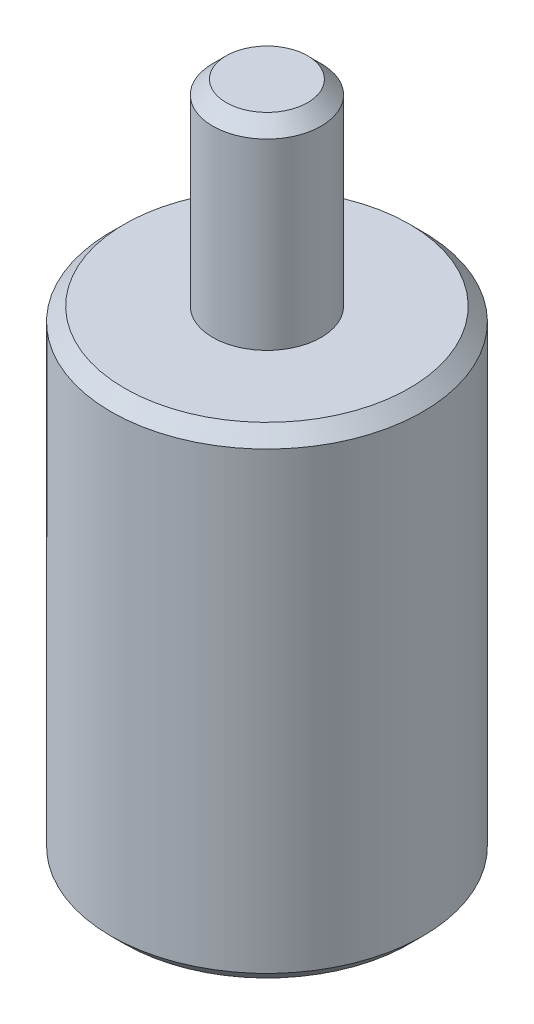
from build123d import *

# Parameters (mm, degrees)
SKETCH1_R           = 1.15
BOSS_EXTRUDE1_DEPTH = 5
SKETCH2_OUTSIDE_W   = 5.492
SKETCH2_OUTSIDE_H   = 5.492
SKETCH2_OUTSIDE_R   = 0.4
CUT_EXTRUDE1_DEPTH  = 1.45
CHAMFER1_SIZE       = 0.1
CHAMFER2_SIZE       = 0.1


with BuildPart() as part:
    # Sketch1 → Boss-Extrude1 (new body)
    with BuildSketch(Plane(origin=(0, 0, 0), x_dir=(1, 0, 0), z_dir=(0, 1, 0))):
        Circle(SKETCH1_R)
    extrude(amount=BOSS_EXTRUDE1_DEPTH)

    # Sketch2 outside → Cut-Extrude1 (cut)
    with BuildSketch(Plane(origin=(0, 5, 0), x_dir=(1, 0, 0), z_dir=(0, 1, 0))):
        Rectangle(SKETCH2_OUTSIDE_W, SKETCH2_OUTSIDE_H)
        Circle(SKETCH2_OUTSIDE_R, mode=Mode.SUBTRACT)
    extrude(amount=-CUT_EXTRUDE1_DEPTH, mode=Mode.SUBTRACT)

    # Chamfer1
    chamfer1_edges = [part.edges().sort_by_distance(p)[0] for p in [
        (-1.15, 0, 0),
        (-1.15, 3.55, 0),
    ]]
    chamfer(chamfer1_edges, length=CHAMFER1_SIZE)

    # Chamfer2
    chamfer2_edges = [part.edges().sort_by_distance(p)[0] for p in [
        (-0.4, 5, 0),
    ]]
    chamfer(chamfer2_edges, length=CHAMFER2_SIZE)

    # Sketch3 → Cut-Revolve1 (revolve, cut)
    with BuildSketch(Plane.XY):
        Polygon((0, 0), (0, 0.8), (0.8, 0), align=None)
    revolve(axis=Axis((0, 5, 0), (0, -1, 0)), mode=Mode.SUBTRACT)


solid = part.part
